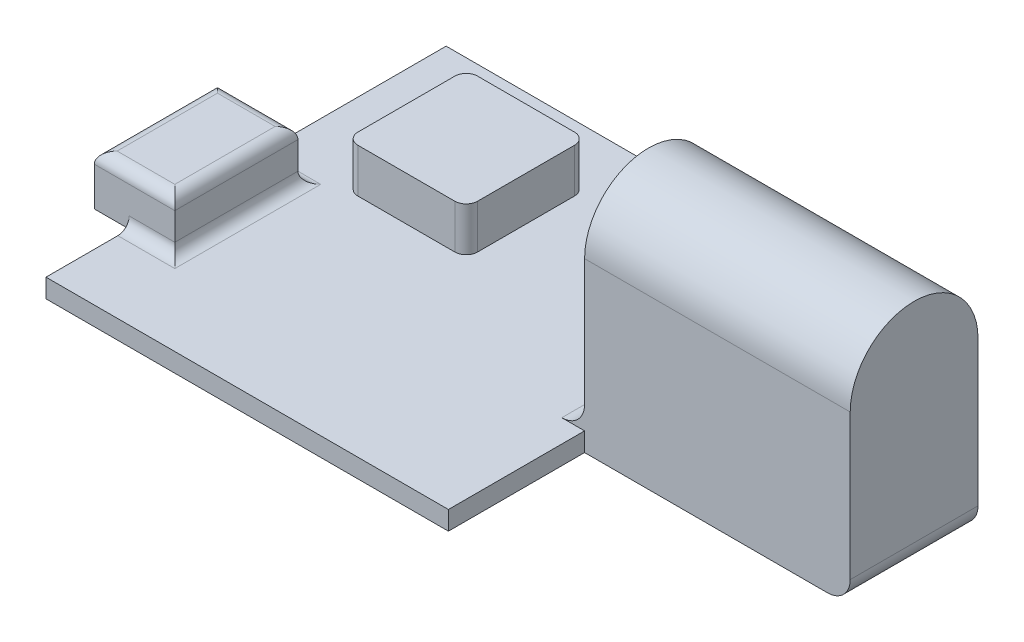
from build123d import *

# Parameters (mm, degrees)
SKETCH1_W           = 10.5
SKETCH1_H           = 10.5
SKETCH1_W_2         = 4
SKETCH1_H_2         = 10.8
BOSS_EXTRUDE1_DEPTH = 1.65
BOSS_EXTRUDE2_START = 1.65
SKETCH1_3_W         = 4
SKETCH1_3_H         = 10.8
SKETCH1_3_W_2       = 3.06
BOSS_EXTRUDE2_DEPTH = 4.4
BOSS_EXTRUDE3_START = 1.65
SKETCH1_4_W         = 10.5
SKETCH1_4_H         = 10.5
BOSS_EXTRUDE3_DEPTH = 3.86
FILLET1_R           = 1
FILLET2_R           = 1
SKETCH2_W           = 7.790130909
SKETCH2_H           = 1.333210324
CUT_EXTRUDE1_DEPTH  = 2
FILLET3_R           = 1
BOSS_EXTRUDE4_DEPTH = 23.3
FILLET4_R           = 2
FILLET5_R           = 2


with BuildPart() as part:
    # Sketch1 → Boss-Extrude1 (new body)
    with BuildSketch(Plane(origin=(0, 0, 0), x_dir=(1, 0, 0), z_dir=(0, 1, 0))):
        Polygon((17.65, 17.55), (-17.65, 17.55), (-17.65, 0.55), (-13.65, 0.55), (-13.65, -10.25), (-17.65, -10.25), (-17.65, -17.55), (17.65, -17.55), align=None)
        with Locations((-5.88, 7.54)):
            Rectangle(SKETCH1_W, SKETCH1_H, mode=Mode.SUBTRACT)
        with Locations((-15.65, -4.85)):
            Rectangle(SKETCH1_W_2, SKETCH1_H_2)
        with Locations((-5.88, 7.54)):
            Rectangle(SKETCH1_W, SKETCH1_H)
    extrude(amount=BOSS_EXTRUDE1_DEPTH)

    # Sketch1_3 → Boss-Extrude2 (add)
    with BuildSketch(Plane(origin=(0, 0, 0), x_dir=(1, 0, 0), z_dir=(0, 1, 0)).offset(BOSS_EXTRUDE2_START)):
        with Locations((-15.65, -4.85)):
            Rectangle(SKETCH1_3_W, SKETCH1_3_H)
        with Locations((-19.18, -4.85)):
            Rectangle(SKETCH1_3_W_2, SKETCH1_3_H)
    extrude(amount=BOSS_EXTRUDE2_DEPTH)

    # Sketch1_4 → Boss-Extrude3 (add)
    with BuildSketch(Plane(origin=(0, 0, 0), x_dir=(1, 0, 0), z_dir=(0, 1, 0)).offset(BOSS_EXTRUDE3_START)):
        with Locations((-5.88, 7.54)):
            Rectangle(SKETCH1_4_W, SKETCH1_4_H)
    extrude(amount=BOSS_EXTRUDE3_DEPTH)

    # Fillet1
    fillet1_edges = [part.edges().sort_by_distance(p)[0] for p in [
        (-15.65, 1.65, 10.25),
        (-15.65, 1.65, -0.55),
        (-13.65, 1.65, 4.85),
    ]]
    fillet(fillet1_edges, radius=FILLET1_R)

    # Fillet2
    fillet2_edges = [part.edges().sort_by_distance(p)[0] for p in [
        (-17.18, 6.05, -0.55),
        (-20.71, 6.05, 4.85),
        (-17.18, 6.05, 10.25),
        (-13.65, 6.05, 4.85),
    ]]
    fillet(fillet2_edges, radius=FILLET2_R)

    # Sketch2 → Cut-Extrude1 (cut)
    with BuildSketch(Plane.ZY.offset(20.71)):
        with Locations((4.993003368, 3.577240422)):
            Rectangle(SKETCH2_W, SKETCH2_H)
    extrude(amount=-CUT_EXTRUDE1_DEPTH, mode=Mode.SUBTRACT)

    # Fillet3
    fillet3_edges = [part.edges().sort_by_distance(p)[0] for p in [
        (-11.13, 3.58, -2.29),
        (-0.63, 3.58, -2.29),
        (-0.63, 3.58, -12.79),
        (-11.13, 3.58, -12.79),
    ]]
    fillet(fillet3_edges, radius=FILLET3_R)

    # Sketch4 → Boss-Extrude4 (add)
    with BuildSketch(Plane(origin=(17.65, 0, 0), x_dir=(0, 0, -1), z_dir=(1, 0, 0))):
        with BuildLine():
            Line((-5.605, 0), (-5.605, 14.732615083))
            ThreePointArc((-5.605, 14.732615083), (0, 20.337615083), (5.605, 14.732615083))
            Line((5.605, 14.732615083), (5.605, 0))
            Line((5.605, 0), (-5.605, 0))
        make_face()
    extrude(amount=BOSS_EXTRUDE4_DEPTH)

    # Fillet4
    fillet4_edges = [part.edges().sort_by_distance(p)[0] for p in [
        (17.65, 1.65, 0),
    ]]
    fillet(fillet4_edges, radius=FILLET4_R)

    # Fillet5
    fillet5_edges = [part.edges().sort_by_distance(p)[0] for p in [
        (40.95, 0, 0),
    ]]
    fillet(fillet5_edges, radius=FILLET5_R)


solid = part.part
